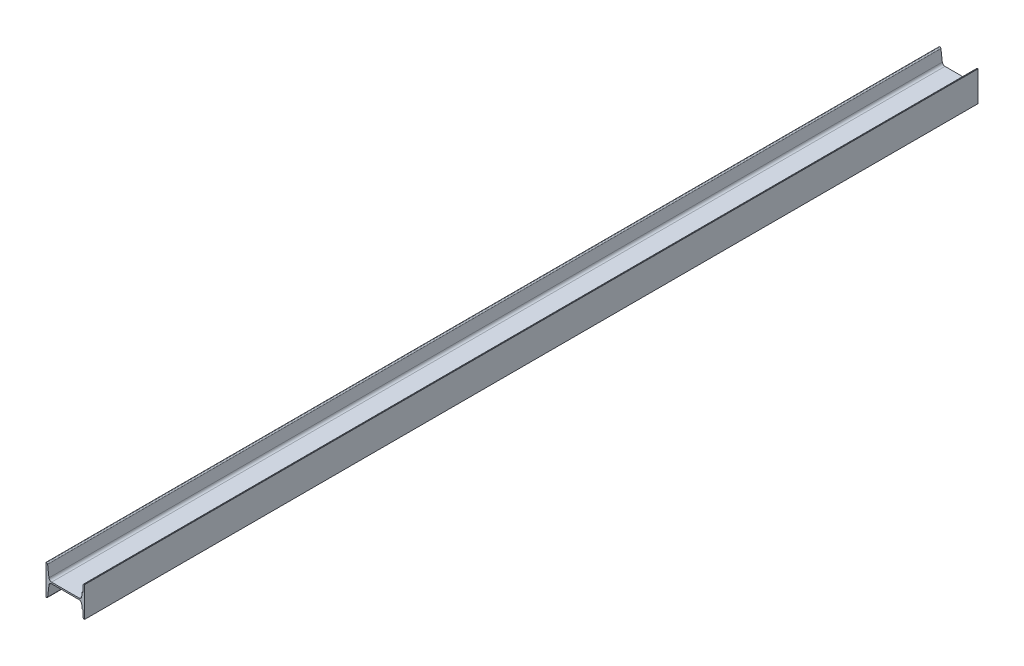
from build123d import *

# Parameters (mm, degrees)
BOSS_EXTRUDE1_DEPTH = 3700
SCALE1_SCALE        = 0.75


with BuildPart() as part:
    # Sketch1 → Boss-Extrude1 (new body)
    with BuildSketch(Plane.XY.offset(1800)):
        with BuildLine():
            Line((129, 60.46884946), (129, 30))
            Line((129, 30), (124.919748757, 30))
            Line((124.919748757, 30), (122.792728308, 12.689402566))
            ThreePointArc((122.792728308, 12.689402566), (119.171200489, 5.771495525), (111.871083085, 3))
            Line((111.871083085, 3), (-1.871083085, 3))
            ThreePointArc((-1.871083085, 3), (-9.171200492, 5.771495528), (-12.792728309, 12.689402573))
            Line((-12.792728309, 12.689402573), (-18.294338419, 58.536153493))
            ThreePointArc((-18.294338419, 58.536153493), (-19.775872526, 61.366206375), (-22.762284192, 62.5))
            Line((-22.762284192, 62.5), (-25, 62.5))
            Line((-25, 62.5), (-25, -62.5))
            Line((-25, -62.5), (-22.762284192, -62.5))
            ThreePointArc((-22.762284192, -62.5), (-19.775872526, -61.366206375), (-18.294338419, -58.536153493))
            Line((-18.294338419, -58.536153493), (-12.792728309, -12.689402573))
            ThreePointArc((-12.792728309, -12.689402573), (-9.171200492, -5.771495528), (-1.871083085, -3))
            Line((-1.871083085, -3), (111.871083085, -3))
            ThreePointArc((111.871083085, -3), (119.171200492, -5.771495528), (122.792728309, -12.689402573))
            Line((122.792728309, -12.689402573), (124.87, -30))
            Line((124.87, -30), (129, -30))
            Line((129, -30), (129, -60.46884946))
            ThreePointArc((129, -60.46884946), (130.62450761, -61.959786773), (132.762284192, -62.5))
            Line((132.762284192, -62.5), (135, -62.5))
            Line((135, -62.5), (135, 62.5))
            Line((135, 62.5), (132.762284192, 62.5))
            ThreePointArc((132.762284192, 62.5), (130.62450761, 61.959786773), (129, 60.46884946))
        make_face()
    extrude(amount=-BOSS_EXTRUDE1_DEPTH)


with BuildPart() as part_1:
    # Scale1: scaled about (51.838667986, -0.00324275, -50)
    add(part.part.scale(SCALE1_SCALE).moved(Location((12.959666996, -0.000810687, -12.5))))


solid = part_1.part
